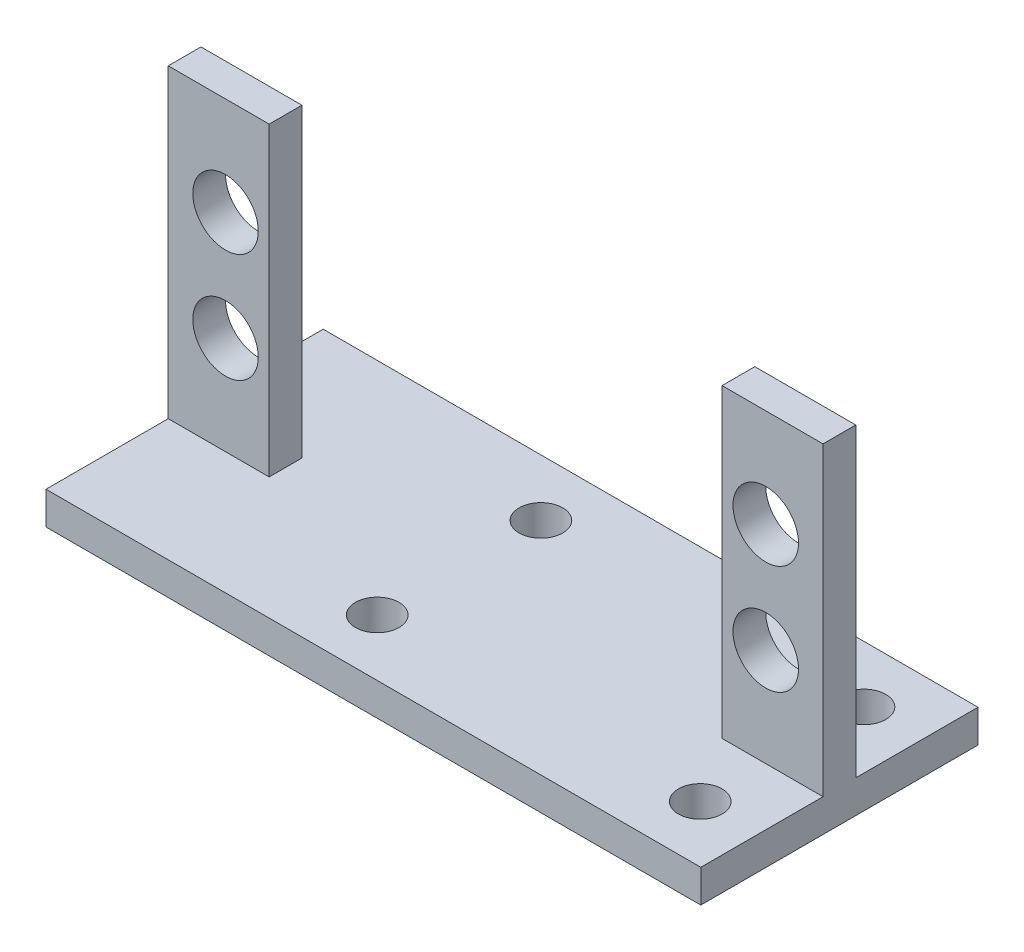
from build123d import *

# Parameters (mm, degrees)
SKETCH_1_W          = 58
SKETCH_1_H          = 25.4
EXTRUDE_1_DEPTH     = 3
SKETCH_2_W          = 8
SKETCH_2_H          = 3
EXTRUDE_2_DEPTH     = 28
SKETCH_3_R          = 3
CUT_EXTRUDE_1_DEPTH = 12
SKETCH_4_R          = 2
CUT_EXTRUDE_2_DEPTH = 22
SKETCH_8_W          = 8
SKETCH_8_H          = 3
CUT_EXTRUDE_3_DEPTH = 28
EXTRUDE_3_DEPTH     = 1
EXTRUDE_4_DEPTH     = 1


with BuildPart() as part:
    # 草图1 → 凸台-拉伸1 (new body)
    with BuildSketch(Plane(origin=(0, 0, 0), x_dir=(1, 0, 0), z_dir=(0, 1, 0))):
        Rectangle(SKETCH_1_W, SKETCH_1_H)
    extrude(amount=EXTRUDE_1_DEPTH)

    # 草图2 → 凸台-拉伸2 (add)
    with BuildSketch(Plane(origin=(0, 3, 0), x_dir=(1, 0, 0), z_dir=(0, 1, 0))):
        with Locations((-24.75, 11.2)):
            Rectangle(SKETCH_2_W, SKETCH_2_H)
        with Locations((24.75, 11.2)):
            Rectangle(SKETCH_2_W, SKETCH_2_H)
        with Locations((-24.75, 0)):
            Rectangle(SKETCH_2_W, SKETCH_2_H)
        with Locations((24.75, 0)):
            Rectangle(SKETCH_2_W, SKETCH_2_H)
    extrude(amount=EXTRUDE_2_DEPTH)

    # 草图3 → 切除-拉伸1 (cut, symmetric)
    with BuildSketch(Plane.XY.offset(-9.7)):
        with Locations((-24.75, 12)):
            Circle(SKETCH_3_R)
        with Locations((-24.75, 22)):
            Circle(SKETCH_3_R)
        with Locations((24.75, 12)):
            Circle(SKETCH_3_R)
        with Locations((24.75, 22)):
            Circle(SKETCH_3_R)
    extrude(amount=CUT_EXTRUDE_1_DEPTH, both=True, mode=Mode.SUBTRACT)

    # 草图4 → 切除-拉伸2 (cut)
    with BuildSketch(Plane(origin=(0, 3, 0), x_dir=(1, 0, 0), z_dir=(0, 1, 0))):
        with Locations((24.75, -7.5)):
            Circle(SKETCH_4_R)
        with Locations((24.75, 7.5)):
            Circle(SKETCH_4_R)
        with Locations((-4.85, 7.5)):
            Circle(SKETCH_4_R)
        with Locations((-4.85, -7.5)):
            Circle(SKETCH_4_R)
    extrude(amount=-CUT_EXTRUDE_2_DEPTH, mode=Mode.SUBTRACT)

    # 草图8 → 切除-拉伸3 (cut)
    with BuildSketch(Plane(origin=(0, 31, 0), x_dir=(1, 0, 0), z_dir=(0, 1, 0))):
        with Locations((-24.75, 11.2)):
            Rectangle(SKETCH_8_W, SKETCH_8_H)
        with Locations((24.75, 11.2)):
            Rectangle(SKETCH_8_W, SKETCH_8_H)
    extrude(amount=-CUT_EXTRUDE_3_DEPTH, mode=Mode.SUBTRACT)

    # 草图9 → 凸台-拉伸3 (add, symmetric)
    with BuildSketch(Plane(origin=(29, 0, 0), x_dir=(0, 0, -1), z_dir=(1, 0, 0))):
        Polygon((-12.7, 3), (-1.5, 3), (-1.5, 31), (1.5, 31), (1.5, 3), (12.7, 3), (12.7, 0), (-12.7, 0), align=None)
    extrude(amount=EXTRUDE_3_DEPTH, both=True)

    # 草图10 → 凸台-拉伸4 (add, symmetric)
    with BuildSketch(Plane.ZY.offset(29)):
        Polygon((-12.7, 3), (-1.5, 3), (-1.5, 31), (1.5, 31), (1.5, 3), (12.7, 3), (12.7, 0), (-12.7, 0), align=None)
    extrude(amount=EXTRUDE_4_DEPTH, both=True)


solid = part.part
